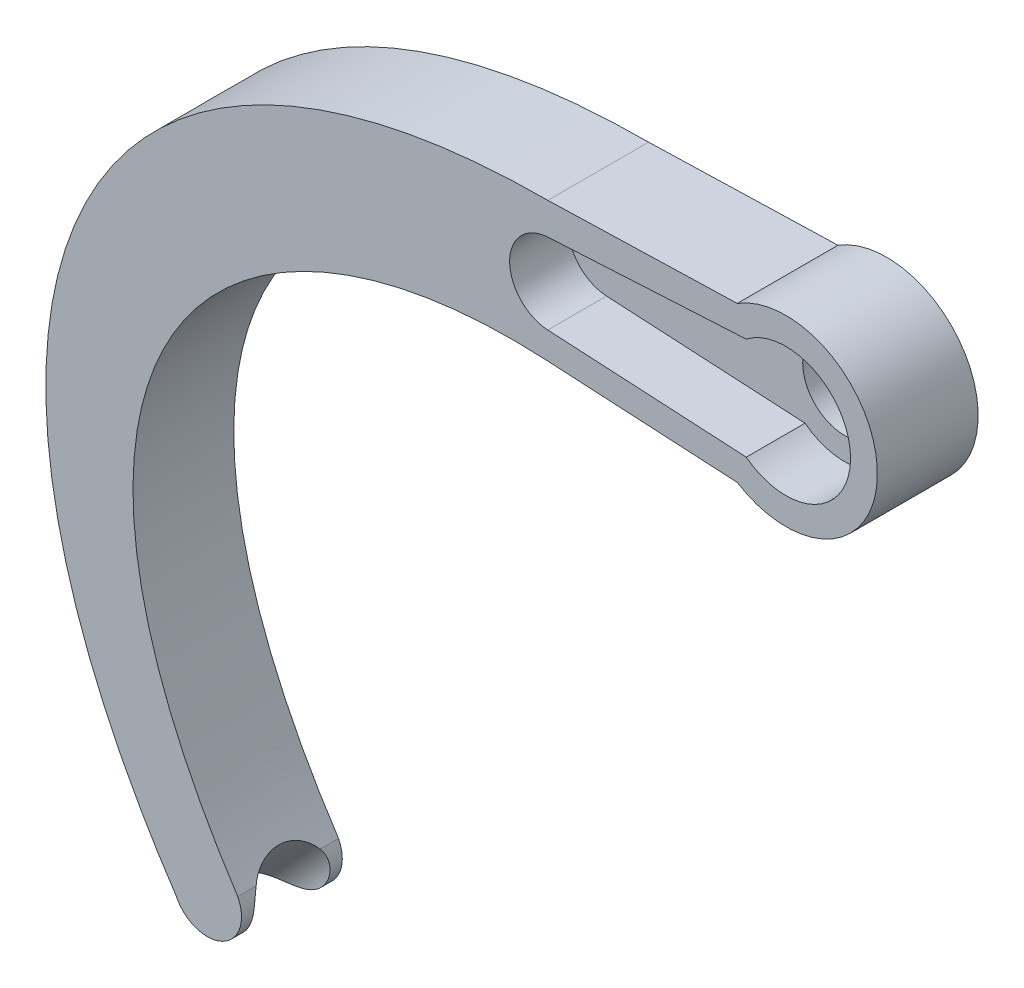
from build123d import *

# Parameters (mm, degrees)
BOSS_EXTRUDE1_DEPTH = 6
CUT_EXTRUDE1_DEPTH  = 3.5
SKETCH4_R           = 2.5
CUT_EXTRUDE2_DEPTH  = 3.5
SKETCH6_RX          = 2.368753343
SKETCH6_RY          = 2.322011883
CUT_EXTRUDE3_DEPTH  = 30


with BuildPart() as part:
    # Sketch1 → Boss-Extrude1 (new body)
    with BuildSketch(Plane.XY):
        with BuildLine():
            Line((-14.268243934, -3.994041761), (-2.898518265, -4.615310593))
            ThreePointArc((-2.898518265, -4.615310593), (5.45, 0), (-2.898518265, 4.615310593))
            Line((-2.898518265, 4.615310593), (-14.17529192, 4.292464798))
            add(Edge.make_bspline(
                [(-14.17529192, 4.292464798), (-42.462260129, 4.288818218), (-52.533757866, -18.372051692), (-36.302785322, -42.655354232)],
                knots=[0, 0, 0, 0, 1, 1, 1, 1], degree=3))
            ThreePointArc((-36.302785322, -42.655354232), (-33.552833422, -43.610103827), (-32.640753317, -40.845706583))
            add(Edge.make_bspline(
                [(-14.268243934, -3.994041761), (-34.73116579, -2.87481632), (-47.018413867, -18.971545605), (-32.640753317, -40.845706583)],
                knots=[0, 0, 0, 0, 1, 1, 1, 1], degree=3))
        make_face()
    extrude(amount=BOSS_EXTRUDE1_DEPTH)

    # Sketch3 → Cut-Extrude1 (cut)
    with BuildSketch(Plane.XY):
        with BuildLine():
            Line((-14.18094636, -2.396425056), (-2.359318085, -3.042386921))
            ThreePointArc((-2.359318085, -3.042386921), (3.85, 0), (-2.359318085, 3.042386921))
            Line((-2.359318085, 3.042386921), (-14.18094636, 2.396425056))
            ThreePointArc((-14.18094636, 2.396425056), (-16.45, 0), (-14.18094636, -2.396425056))
        make_face()
    extrude(amount=CUT_EXTRUDE1_DEPTH, mode=Mode.SUBTRACT)

    # Sketch4 → Cut-Extrude2 (cut)
    with BuildSketch(Plane(origin=(0, 0, 3.5), x_dir=(-1, 0, 0), z_dir=(0, 0, -1))):
        Circle(SKETCH4_R)
    extrude(amount=-CUT_EXTRUDE2_DEPTH, mode=Mode.SUBTRACT)

    # Sketch6 → Cut-Extrude3 (cut)
    with BuildSketch(Plane(origin=(-23.619287881, -25.215704234, 0), x_dir=(0, 0, -1), z_dir=(0.683626277, 0.72983225, 0))):
        with Locations(Location((-3, -5.45537074), (0, 0, -90))):
            Ellipse(SKETCH6_RX, SKETCH6_RY)
    extrude(amount=-CUT_EXTRUDE3_DEPTH, mode=Mode.SUBTRACT)


with BuildPart() as body_2:
    # Mirror3: mirrored copy
    add(part.part.mirror(Plane(origin=(0, 0, -40), x_dir=(1, 0, 0), z_dir=(0, 0, -1))))


solid = body_2.part
